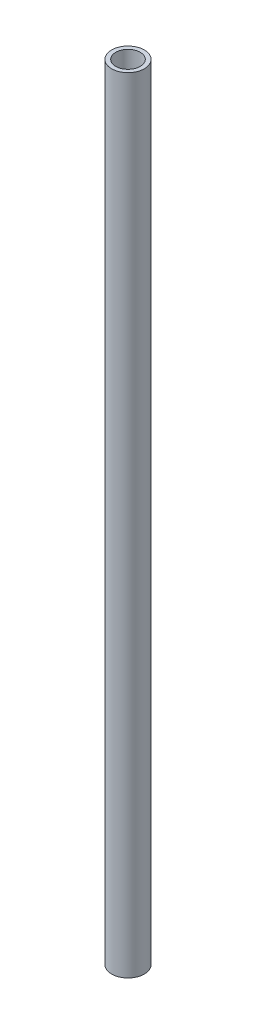
from build123d import *

# Parameters (mm, degrees)
SKETCH1_R           = 12.7
SKETCH1_R_2         = 9.525
BOSS_EXTRUDE1_DEPTH = 609.6


with BuildPart() as part:
    # Sketch1 → Boss-Extrude1 (new body)
    with BuildSketch(Plane(origin=(0, 0, 0), x_dir=(1, 0, 0), z_dir=(0, 1, 0))):
        Circle(SKETCH1_R)
        Circle(SKETCH1_R_2, mode=Mode.SUBTRACT)
    extrude(amount=BOSS_EXTRUDE1_DEPTH)


solid = part.part
